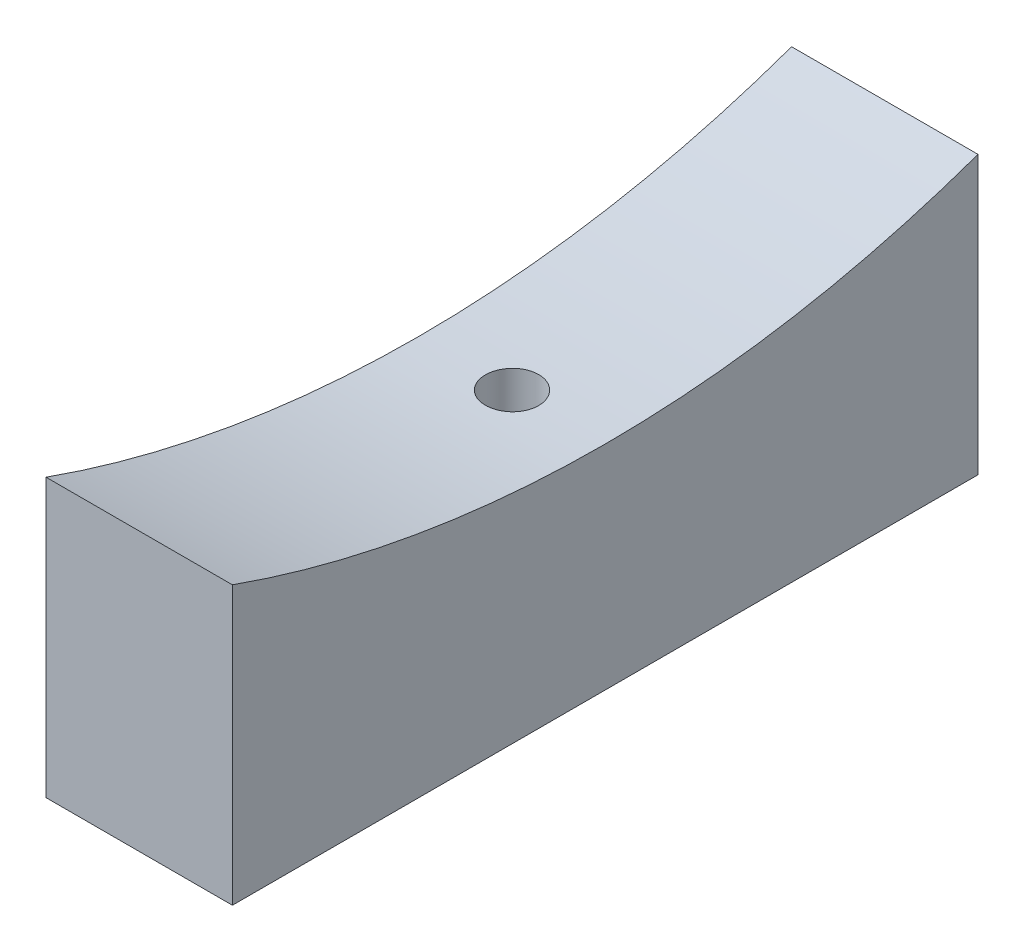
from build123d import *

# Parameters (mm, degrees)
BOSS_EXTRU_1_DEPTH      = 21
ENL_V_MAT_EXTRU_1_REACH = 33.267
ESQUISSE2_R             = 3
ESQUISSE3_R             = 6
ENL_V_MAT_EXTRU_2_DEPTH = 10


with BuildPart() as part:
    # Esquisse1 → Boss.-Extru.1 (new body)
    with BuildSketch(Plane(origin=(0, 0, 0), x_dir=(0, 0, -1), z_dir=(1, 0, 0))):
        with BuildLine():
            Line((-42, -117.732748205), (-42, -149))
            Line((-42, -149), (42, -149))
            Line((42, -149), (42, -117.732748205))
            ThreePointArc((42, -117.732748205), (0, -125), (-42, -117.732748205))
        make_face()
    extrude(amount=BOSS_EXTRU_1_DEPTH)

    # Esquisse2 → Enlèv. mat.-Extru.1 (cut, up to next)
    with BuildSketch(Plane.XZ.offset(149), mode=Mode.PRIVATE) as enl_v_mat_extru_1_sk1:
        with Locations((10.5, 0)):
            Circle(ESQUISSE2_R)
    enl_v_mat_extru_1_tool1 = extrude(enl_v_mat_extru_1_sk1.sketch, amount=-ENL_V_MAT_EXTRU_1_REACH, mode=Mode.PRIVATE) & part.part
    add(enl_v_mat_extru_1_tool1.solids().sort_by_distance((10.5, -149, 0))[0], mode=Mode.SUBTRACT)

    # Esquisse3 → Enlèv. mat.-Extru.2 (cut)
    with BuildSketch(Plane.XZ.offset(149)):
        with Locations((10.560210211, 0)):
            Circle(ESQUISSE3_R)
    extrude(amount=-ENL_V_MAT_EXTRU_2_DEPTH, mode=Mode.SUBTRACT)


solid = part.part
